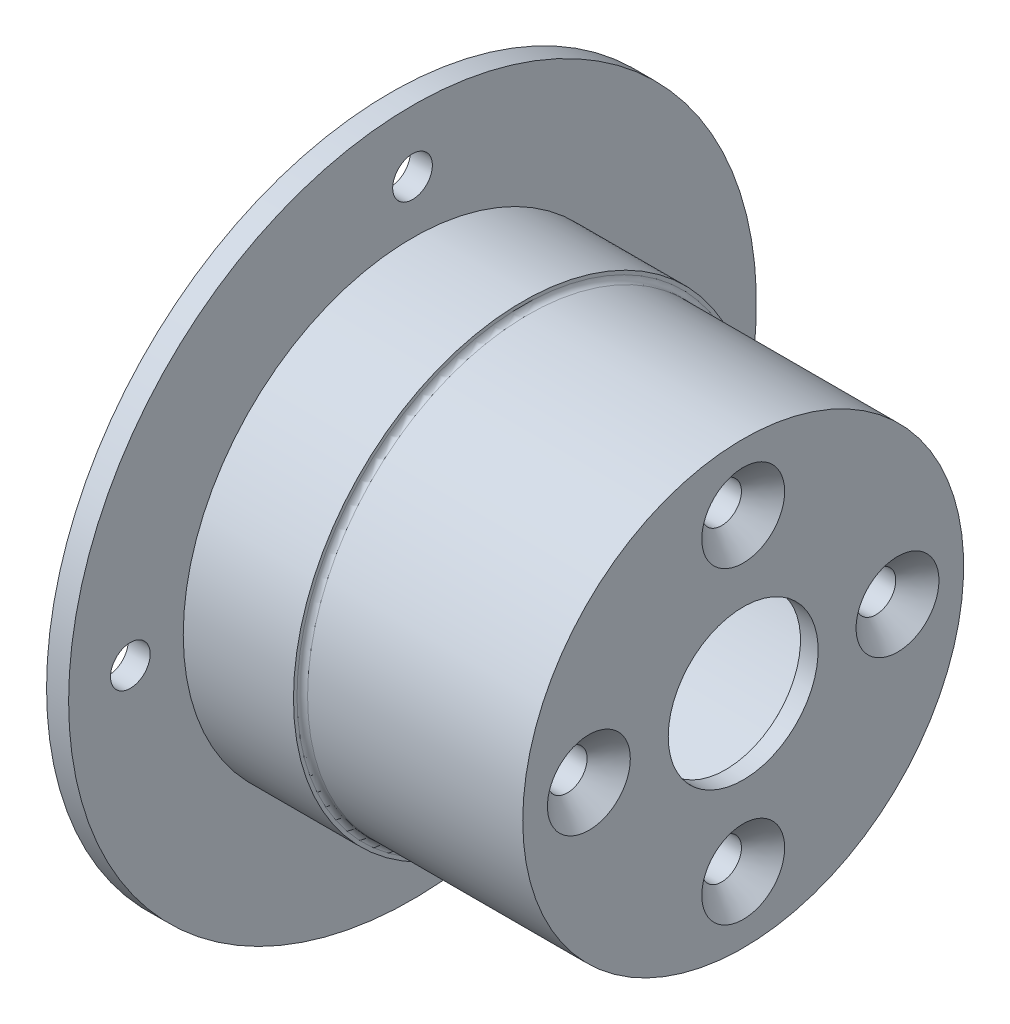
from build123d import *

# Parameters (mm, degrees)
CSK_FOR_M4_FLAT_HEAD_MACHINE_SCREW1_D           = 4.5
CSK_FOR_M4_FLAT_HEAD_MACHINE_SCREW1_DEPTH       = 5
CSK_FOR_M4_FLAT_HEAD_MACHINE_SCREW1_CSINK_D     = 9.4
CSK_FOR_M4_FLAT_HEAD_MACHINE_SCREW1_CSINK_ANGLE = 90
FILLET1_R                                       = 0.6
M4_CLEARANCE_HOLE1_D                            = 4.5
M4_CLEARANCE_HOLE1_DEPTH                        = 2.5


with BuildPart() as part:
    # Sketch2 → Revolve1 (revolve)
    with BuildSketch(Plane.XY):
        Polygon((0, 21), (35, 21), (35, 12.75), (38, 12.75), (38, 8.5), (40, 8.5), (40, 25), (15, 25), (15, 26), (2.5, 26), (2.5, 39), (0, 39), (0, 26), align=None)
    revolve(axis=Axis((-64.103352454, 0, 0), (1, 0, 0)))

    # CSK for M4 Flat Head Machine Screw1
    with Locations(Plane(origin=(40, 0, 0), x_dir=(0, 0, -1), z_dir=(1, 0, 0))):
        with Locations((0, 17.5), (17.5, 0), (0, -17.5), (-17.5, 0)):
            CounterSinkHole(CSK_FOR_M4_FLAT_HEAD_MACHINE_SCREW1_D / 2, CSK_FOR_M4_FLAT_HEAD_MACHINE_SCREW1_CSINK_D / 2, depth=CSK_FOR_M4_FLAT_HEAD_MACHINE_SCREW1_DEPTH, counter_sink_angle=CSK_FOR_M4_FLAT_HEAD_MACHINE_SCREW1_CSINK_ANGLE)

    # Fillet1
    fillet1_edges = [part.edges().sort_by_distance(p)[0] for p in [
        (15, -25, 0),
    ]]
    fillet(fillet1_edges, radius=FILLET1_R)

    # M4 Clearance Hole1
    with Locations(Plane.ZY):
        with Locations((0, 32), (0, -32), (32, 0), (-32, 0)):
            Hole(M4_CLEARANCE_HOLE1_D / 2, depth=M4_CLEARANCE_HOLE1_DEPTH)


solid = part.part
